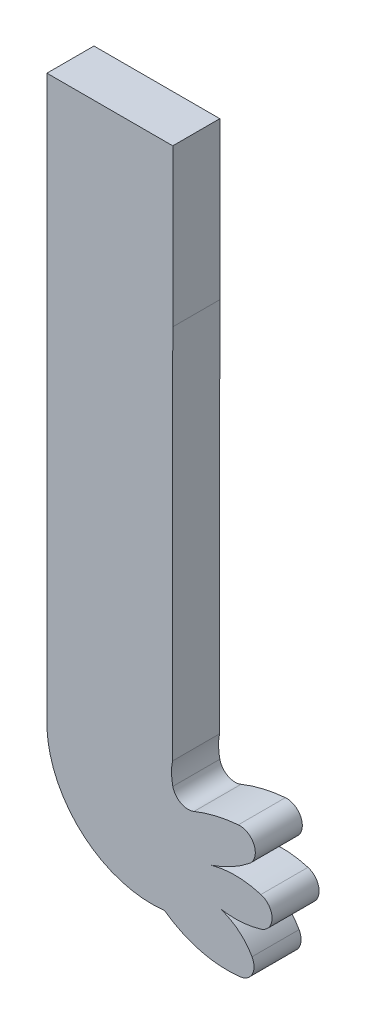
from build123d import *

# Parameters (mm, degrees)
SALIENTE_EXTRUIR1_DEPTH = 3


with BuildPart() as part:
    # Model → Saliente-Extruir1 (new body)
    with BuildSketch(Plane.XY):
        with BuildLine():
            Line((27.467941077, 39.680349578), (27.467941077, 22.097099578))
            Line((27.467941077, 22.097099578), (27.467941077, 3.513849578))
            ThreePointArc((27.467941077, 3.513849578), (29.833805345, -1.291965393), (34.967941077, -2.819650422))
            ThreePointArc((34.967941077, -2.819650422), (37.2653644, -3.903815719), (39.800359504, -4.069248896))
            ThreePointArc((39.800359504, -4.069248896), (40.5704791, -3.527774359), (40.549576341, -2.586582592))
            ThreePointArc((40.549576341, -2.586582592), (39.682712456, -1.563786177), (38.497352842, -0.937297481))
            ThreePointArc((38.497352842, -0.937297481), (39.816352512, -1.009870934), (41.116644878, -0.776918583))
            ThreePointArc((41.116644878, -0.776918583), (41.8274431, 0.180349578), (41.116644878, 1.137617739))
            ThreePointArc((41.116644878, 1.137617739), (39.545301969, 1.380701786), (37.967941077, 1.180349578))
            ThreePointArc((37.967941077, 1.180349578), (39.230469791, 1.72740936), (40.379023795, 2.485087958))
            ThreePointArc((40.379023795, 2.485087958), (40.687813038, 3.636299223), (39.675412289, 4.265332526))
            ThreePointArc((39.675412289, 4.265332526), (38.236782457, 4.035665244), (36.849346326, 3.591341219))
            ThreePointArc((36.849346326, 3.591341219), (36.009082944, 3.632037192), (35.497205789, 4.299630249))
            ThreePointArc((35.497205789, 4.299630249), (35.415004717, 4.995458697), (35.476051331, 5.693461244))
            Line((35.476051331, 5.693461244), (35.493981077, 29.680349578))
            Line((35.493981077, 29.680349578), (35.493981077, 39.680349578))
            Line((35.493981077, 39.680349578), (27.467941077, 39.680349578))
        make_face()
    extrude(amount=SALIENTE_EXTRUIR1_DEPTH)


solid = part.part
